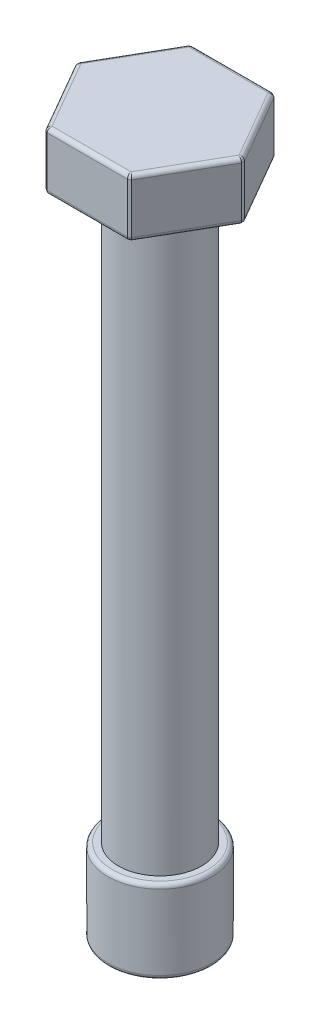
from build123d import *

# Parameters (mm, degrees)
CUT_EXTRUDE2_START = -2.8
SKETCH2_R          = 4.777548175
CUT_EXTRUDE2_DEPTH = 2.8
CUT_EXTRUDE3_DEPTH = 2.7
FILLET1_R          = 0.2


with BuildPart() as part:
    # Sketch1 → Revolve1 (revolve)
    with BuildSketch(Plane.XY):
        Polygon((0, 34.58), (-4, 34.58), (-4, 31.78), (-2, 31.78), (-2, 4), (-2.5, 4), (-2.5, 0), (0, 0), align=None)
    revolve(axis=Axis((0, 37.671641791, 0), (0, -1, 0)))

    # Sketch2 → Cut-Extrude2 (cut)
    with BuildSketch(Plane(origin=(0, 34.58, 0), x_dir=(1, 0, 0), z_dir=(0, 1, 0)).offset(CUT_EXTRUDE2_START)):
        Circle(SKETCH2_R)
        Polygon((-4.041451884, 0), (-2.020725942, -3.5), (2.020725942, -3.5), (4.041451884, 0), (2.020725942, 3.5), (-2.020725942, 3.5), align=None, mode=Mode.SUBTRACT)
    extrude(amount=CUT_EXTRUDE2_DEPTH, mode=Mode.SUBTRACT)

    # Sketch3 → Cut-Extrude3 (cut)
    with BuildSketch(Plane.XZ):
        Polygon((0, 1.732050808), (-1.5, 0.866025404), (-1.5, -0.866025404), (0, -1.732050808), (1.5, -0.866025404), (1.5, 0.866025404), align=None)
    extrude(amount=-CUT_EXTRUDE3_DEPTH, mode=Mode.SUBTRACT)

    # Fillet1
    fillet1_edges = [part.edges().sort_by_distance(p)[0] for p in [
        (4, 31.78, 0),
        (2, 31.78, -3.464101615),
        (-2, 31.78, -3.464101615),
        (-4, 31.78, 0),
        (-2, 31.78, 3.464101615),
        (4, 34.58, 0),
        (2, 34.58, -3.464101615),
        (-2, 34.58, -3.464101615),
        (-4, 34.58, 0),
        (-2, 34.58, 3.464101615),
        (3.031088913, 34.58, -1.75),
        (3.031088913, 34.58, 1.75),
        (0, 34.58, 3.5),
        (-3.031088913, 34.58, 1.75),
        (-3.031088913, 34.58, -1.75),
        (0, 34.58, -3.5),
        (-3.031088913, 31.78, -1.75),
        (-3.031088913, 31.78, 1.75),
        (0, 31.78, 3.5),
        (3.031088913, 31.78, 1.75),
        (3.031088913, 31.78, -1.75),
        (0, 31.78, -3.5),
        (2.5, 0, 0),
        (2.5, 4, 0),
        (2, 31.78, 0),
        (2, 31.78, 3.464101615),
        (2, 34.58, 3.464101615),
    ]]
    fillet(fillet1_edges, radius=FILLET1_R)


solid = part.part
